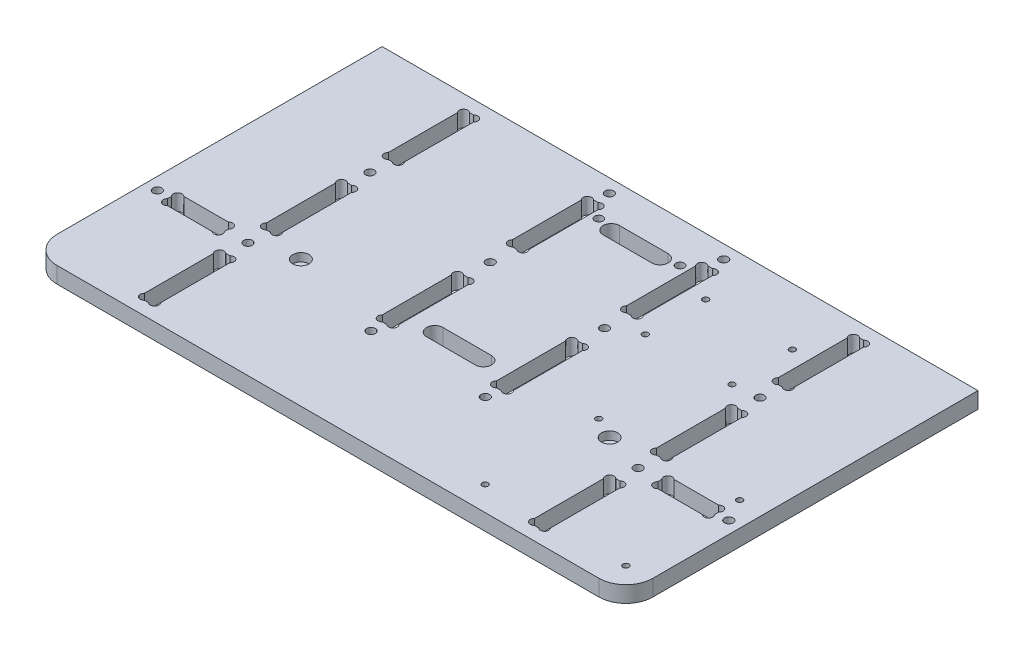
from build123d import *

# Parameters (mm, degrees)
ESQUISSE2_R             = 1.6
ESQUISSE2_R_2           = 1.1
EXTRUSION1_DEPTH        = 6
ESQUISSE4_R             = 1.53
ESQUISSE4_R_2           = 3
ENL_V_MAT_EXTRU_2_DEPTH = 3


with BuildPart() as part:
    # Esquisse2 → Extrusion1 (new body)
    with BuildSketch(Plane(origin=(0, 0, 0), x_dir=(1, 0, 0), z_dir=(0, 1, 0))):
        with BuildLine():
            Line((-30, 10), (-30, 130))
            Line((-30, 130), (190, 130))
            Line((190, 130), (190, 10))
            ThreePointArc((190, 10), (187.071067812, 2.928932188), (180, 0))
            Line((180, 0), (-20, 0))
            ThreePointArc((-20, 0), (-27.071067812, 2.928932188), (-30, 10))
        make_face()
        with Locations(Location((8, 87.5, 0), (0, 0, 270))):  # turned: the seam where the file's is
            Circle(ESQUISSE2_R, mode=Mode.SUBTRACT)
        with Locations(Location((8, 42.5, 0), (0, 0, 90))):  # turned: the seam where the file's is
            Circle(ESQUISSE2_R, mode=Mode.SUBTRACT)
        with Locations(Location((152, 42.5, 0), (0, 0, 270))):  # turned: the seam where the file's is
            Circle(ESQUISSE2_R, mode=Mode.SUBTRACT)
        with Locations(Location((152, 87.5, 0), (0, 0, 90))):  # turned: the seam where the file's is
            Circle(ESQUISSE2_R, mode=Mode.SUBTRACT)
        with Locations(Location((58.9, 125, 0), (0, 0, 270))):  # turned: the seam where the file's is
            Circle(ESQUISSE2_R, mode=Mode.SUBTRACT)
        with Locations(Location((110.6, 108.86, 0), (0, 0, 270))):  # turned: the seam where the file's is
            Circle(ESQUISSE2_R_2, mode=Mode.SUBTRACT)
        with Locations(Location((-25.5, 42.5, 0), (0, 0, 270))):  # turned: the seam where the file's is
            Circle(ESQUISSE2_R, mode=Mode.SUBTRACT)
        with Locations(Location((185.5, 42.5, 0), (0, 0, 90))):  # turned: the seam where the file's is
            Circle(ESQUISSE2_R, mode=Mode.SUBTRACT)
        with Locations(Location((110.6, 86.56, 0), (0, 0, 270))):  # turned: the seam where the file's is
            Circle(ESQUISSE2_R_2, mode=Mode.SUBTRACT)
        with Locations(Location((58.9, 81, 0), (0, 0, 270))):  # turned: the seam where the file's is
            Circle(ESQUISSE2_R, mode=Mode.SUBTRACT)
        with Locations(Location((58.9, 37, 0), (0, 0, 90))):  # turned: the seam where the file's is
            Circle(ESQUISSE2_R, mode=Mode.SUBTRACT)
        with Locations(Location((101.1, 37, 0), (0, 0, 270))):  # turned: the seam where the file's is
            Circle(ESQUISSE2_R, mode=Mode.SUBTRACT)
        with Locations(Location((101.1, 81, 0), (0, 0, 90))):  # turned: the seam where the file's is
            Circle(ESQUISSE2_R, mode=Mode.SUBTRACT)
        with Locations(Location((101.1, 125, 0), (0, 0, 90))):  # turned: the seam where the file's is
            Circle(ESQUISSE2_R, mode=Mode.SUBTRACT)
        with Locations(Location((142.6, 108.86, 0), (0, 0, 90))):  # turned: the seam where the file's is
            Circle(ESQUISSE2_R_2, mode=Mode.SUBTRACT)
        with Locations(Location((142.6, 86.56, 0), (0, 0, 90))):  # turned: the seam where the file's is
            Circle(ESQUISSE2_R_2, mode=Mode.SUBTRACT)
        with Locations(Location((181, 9, 0), (0, 0, 270))):  # turned: the seam where the file's is
            Circle(ESQUISSE2_R_2, mode=Mode.SUBTRACT)
        with Locations(Location((129, 9, 0), (0, 0, 90))):  # turned: the seam where the file's is
            Circle(ESQUISSE2_R_2, mode=Mode.SUBTRACT)
        with Locations(Location((129, 51, 0), (0, 0, 270))):  # turned: the seam where the file's is
            Circle(ESQUISSE2_R_2, mode=Mode.SUBTRACT)
        with Locations(Location((181, 51, 0), (0, 0, 90))):  # turned: the seam where the file's is
            Circle(ESQUISSE2_R_2, mode=Mode.SUBTRACT)
        with BuildLine():
            Line((7.2627417, 125), (8.7372583, 125))
            ThreePointArc((8.7372583, 125), (11, 125), (11, 122.7372583))
            Line((11, 122.7372583), (11, 97.2627417))
            ThreePointArc((11, 97.2627417), (11, 95), (8.7372583, 95))
            Line((8.7372583, 95), (7.2627417, 95))
            ThreePointArc((7.2627417, 95), (5, 95), (5, 97.2627417))
            Line((5, 97.2627417), (5, 122.7372583))
            ThreePointArc((5, 122.7372583), (5, 125), (7.2627417, 125))
        make_face(mode=Mode.SUBTRACT)
        with BuildLine():
            Line((7.2627417, 80), (8.7372583, 80))
            ThreePointArc((8.7372583, 80), (11, 80), (11, 77.7372583))
            Line((11, 77.7372583), (11, 52.2627417))
            ThreePointArc((11, 52.2627417), (11, 50), (8.7372583, 50))
            Line((8.7372583, 50), (7.2627417, 50))
            ThreePointArc((7.2627417, 50), (5, 50), (5, 52.2627417))
            Line((5, 52.2627417), (5, 77.7372583))
            ThreePointArc((5, 77.7372583), (5, 80), (7.2627417, 80))
        make_face(mode=Mode.SUBTRACT)
        with BuildLine():
            Line((8.7372583, 35), (7.2627417, 35))
            ThreePointArc((7.2627417, 35), (5, 35), (5, 32.7372583))
            Line((5, 32.7372583), (5, 7.2627417))
            ThreePointArc((5, 7.2627417), (5, 5), (7.2627417, 5))
            Line((7.2627417, 5), (8.7372583, 5))
            ThreePointArc((8.7372583, 5), (11, 5), (11, 7.2627417))
            Line((11, 7.2627417), (11, 32.7372583))
            ThreePointArc((11, 32.7372583), (11, 35), (8.7372583, 35))
        make_face(mode=Mode.SUBTRACT)
        with BuildLine():
            Line((152.7372583, 5), (151.2627417, 5))
            ThreePointArc((151.2627417, 5), (149, 5), (149, 7.2627417))
            Line((149, 7.2627417), (149, 32.7372583))
            ThreePointArc((149, 32.7372583), (149, 35), (151.2627417, 35))
            Line((151.2627417, 35), (152.7372583, 35))
            ThreePointArc((152.7372583, 35), (155, 35), (155, 32.7372583))
            Line((155, 32.7372583), (155, 7.2627417))
            ThreePointArc((155, 7.2627417), (155, 5), (152.7372583, 5))
        make_face(mode=Mode.SUBTRACT)
        with BuildLine():
            Line((155, 77.7372583), (155, 52.2627417))
            ThreePointArc((155, 52.2627417), (155, 50), (152.7372583, 50))
            Line((152.7372583, 50), (151.2627417, 50))
            ThreePointArc((151.2627417, 50), (149, 50), (149, 52.2627417))
            Line((149, 52.2627417), (149, 77.7372583))
            ThreePointArc((149, 77.7372583), (149, 80), (151.2627417, 80))
            Line((151.2627417, 80), (152.7372583, 80))
            ThreePointArc((152.7372583, 80), (155, 80), (155, 77.7372583))
        make_face(mode=Mode.SUBTRACT)
        with BuildLine():
            Line((151.2627417, 95), (152.7372583, 95))
            ThreePointArc((152.7372583, 95), (155, 95), (155, 97.2627417))
            Line((155, 97.2627417), (155, 122.7372583))
            ThreePointArc((155, 122.7372583), (155, 125), (152.7372583, 125))
            Line((152.7372583, 125), (151.2627417, 125))
            ThreePointArc((151.2627417, 125), (149, 125), (149, 122.7372583))
            Line((149, 122.7372583), (149, 97.2627417))
            ThreePointArc((149, 97.2627417), (149, 95), (151.2627417, 95))
        make_face(mode=Mode.SUBTRACT)
        with BuildLine():
            Line((181, 41.7627417), (181, 43.2372583))
            ThreePointArc((181, 43.2372583), (181, 45.5), (178.7372583, 45.5))
            Line((178.7372583, 45.5), (162.2627417, 45.5))
            ThreePointArc((162.2627417, 45.5), (160, 45.5), (160, 43.2372583))
            Line((160, 43.2372583), (160, 41.7627417))
            ThreePointArc((160, 41.7627417), (160, 39.5), (162.2627417, 39.5))
            Line((162.2627417, 39.5), (178.7372583, 39.5))
            ThreePointArc((178.7372583, 39.5), (181, 39.5), (181, 41.7627417))
        make_face(mode=Mode.SUBTRACT)
        with BuildLine():
            Line((-2.2627417, 39.5), (-18.7372583, 39.5))
            ThreePointArc((-18.7372583, 39.5), (-21, 39.5), (-21, 41.7627417))
            Line((-21, 41.7627417), (-21, 43.2372583))
            ThreePointArc((-21, 43.2372583), (-21, 45.5), (-18.7372583, 45.5))
            Line((-18.7372583, 45.5), (-2.2627417, 45.5))
            ThreePointArc((-2.2627417, 45.5), (0, 45.5), (0, 43.2372583))
            Line((0, 43.2372583), (0, 41.7627417))
            ThreePointArc((0, 41.7627417), (0, 39.5), (-2.2627417, 39.5))
        make_face(mode=Mode.SUBTRACT)
        with BuildLine():
            Line((71, 51.4), (89, 51.4))
            ThreePointArc((89, 51.4), (92, 48.4), (89, 45.4))
            Line((89, 45.4), (71, 45.4))
            ThreePointArc((71, 45.4), (68, 48.4), (71, 51.4))
        make_face(mode=Mode.SUBTRACT)
        with BuildLine():
            Line((89, 116.6), (71, 116.6))
            ThreePointArc((71, 116.6), (68, 113.6), (71, 110.6))
            Line((71, 110.6), (89, 110.6))
            ThreePointArc((89, 110.6), (92, 113.6), (89, 116.6))
        make_face(mode=Mode.SUBTRACT)
        with BuildLine():
            Line((62, 44.2627417), (62, 69.7372583))
            ThreePointArc((62, 69.7372583), (62, 72), (59.7372583, 72))
            Line((59.7372583, 72), (58.0627417, 72))
            ThreePointArc((58.0627417, 72), (55.8, 72), (55.8, 69.7372583))
            Line((55.8, 69.7372583), (55.8, 44.2627417))
            ThreePointArc((55.8, 44.2627417), (55.8, 42), (58.0627417, 42))
            Line((58.0627417, 42), (59.7372583, 42))
            ThreePointArc((59.7372583, 42), (62, 42), (62, 44.2627417))
        make_face(mode=Mode.SUBTRACT)
        with BuildLine():
            Line((58.0627417, 120), (59.7372583, 120))
            ThreePointArc((59.7372583, 120), (62, 120), (62, 117.7372583))
            Line((62, 117.7372583), (62, 92.2627417))
            ThreePointArc((62, 92.2627417), (62, 90), (59.7372583, 90))
            Line((59.7372583, 90), (58.0627417, 90))
            ThreePointArc((58.0627417, 90), (55.8, 90), (55.8, 92.2627417))
            Line((55.8, 92.2627417), (55.8, 117.7372583))
            ThreePointArc((55.8, 117.7372583), (55.8, 120), (58.0627417, 120))
        make_face(mode=Mode.SUBTRACT)
        with BuildLine():
            Line((101.9372583, 42), (100.2627417, 42))
            ThreePointArc((100.2627417, 42), (98, 42), (98, 44.2627417))
            Line((98, 44.2627417), (98, 69.7372583))
            ThreePointArc((98, 69.7372583), (98, 72), (100.2627417, 72))
            Line((100.2627417, 72), (101.9372583, 72))
            ThreePointArc((101.9372583, 72), (104.2, 72), (104.2, 69.7372583))
            Line((104.2, 69.7372583), (104.2, 44.2627417))
            ThreePointArc((104.2, 44.2627417), (104.2, 42), (101.9372583, 42))
        make_face(mode=Mode.SUBTRACT)
        with BuildLine():
            Line((101.9372583, 90), (100.2627417, 90))
            ThreePointArc((100.2627417, 90), (98, 90), (98, 92.2627417))
            Line((98, 92.2627417), (98, 117.7372583))
            ThreePointArc((98, 117.7372583), (98, 120), (100.2627417, 120))
            Line((100.2627417, 120), (101.9372583, 120))
            ThreePointArc((101.9372583, 120), (104.2, 120), (104.2, 117.7372583))
            Line((104.2, 117.7372583), (104.2, 92.2627417))
            ThreePointArc((104.2, 92.2627417), (104.2, 90), (101.9372583, 90))
        make_face(mode=Mode.SUBTRACT)
    extrude(amount=EXTRUSION1_DEPTH)

    # Esquisse4 → Enlèv. mat.-Extru.2 (cut)
    with BuildSketch(Plane(origin=(0, 6, 0), x_dir=(-1, 0, 0), z_dir=(0, 1, 0))):
        with Locations(Location((-65, -115, 0), (0, 0, 90))):  # turned: the seam where the file's is
            Circle(ESQUISSE4_R)
        with Locations(Location((-23, -47, 0), (0, 0, 90))):  # turned: the seam where the file's is
            Circle(ESQUISSE4_R_2)
        with Locations(Location((-95, -115, 0), (0, 0, 270))):  # turned: the seam where the file's is
            Circle(ESQUISSE4_R)
        with Locations(Location((-137, -47, 0), (0, 0, 270))):  # turned: the seam where the file's is
            Circle(ESQUISSE4_R_2)
    extrude(amount=-ENL_V_MAT_EXTRU_2_DEPTH, mode=Mode.SUBTRACT)


solid = part.part
